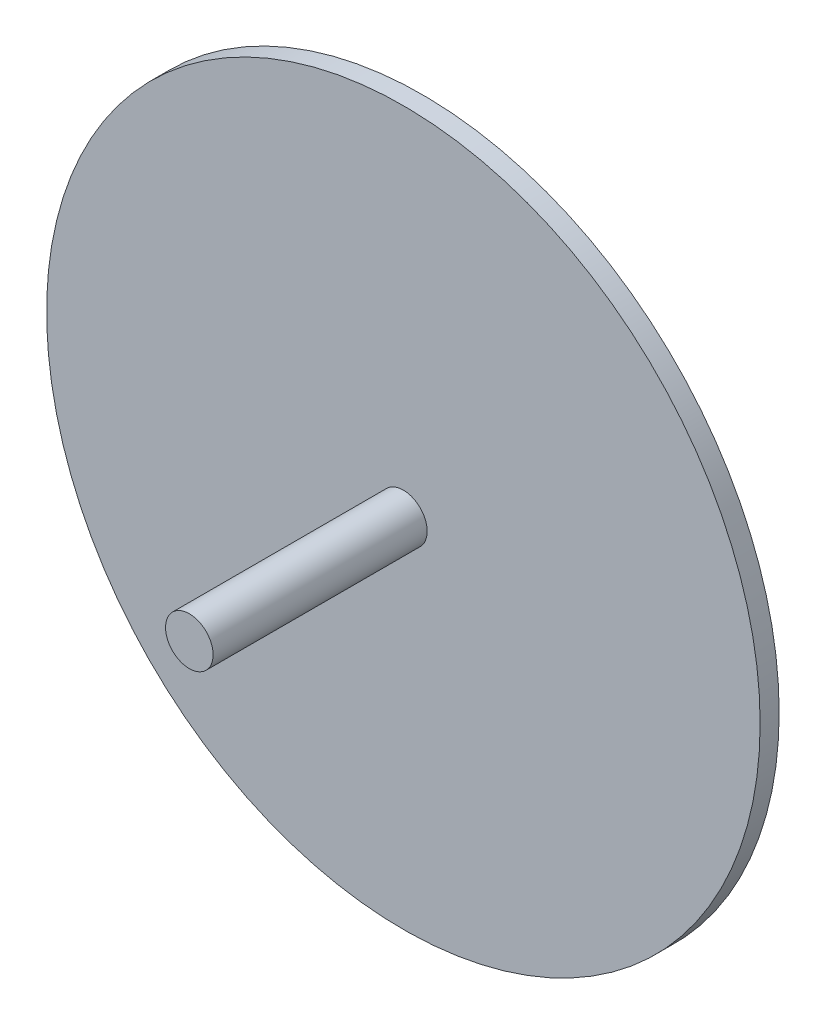
from build123d import *

# Parameters (mm, degrees)
SKETCH2_R           = 75
BOSS_EXTRUDE1_DEPTH = 4
SKETCH3_R           = 5
BOSS_EXTRUDE2_DEPTH = 45


with BuildPart() as part:
    # Sketch2 → Boss-Extrude1 (new body)
    with BuildSketch(Plane.XY):
        Circle(SKETCH2_R)
    extrude(amount=BOSS_EXTRUDE1_DEPTH)

    # Sketch3 → Boss-Extrude2 (add)
    with BuildSketch(Plane.XY.offset(4)):
        Circle(SKETCH3_R)
    extrude(amount=BOSS_EXTRUDE2_DEPTH)


solid = part.part
